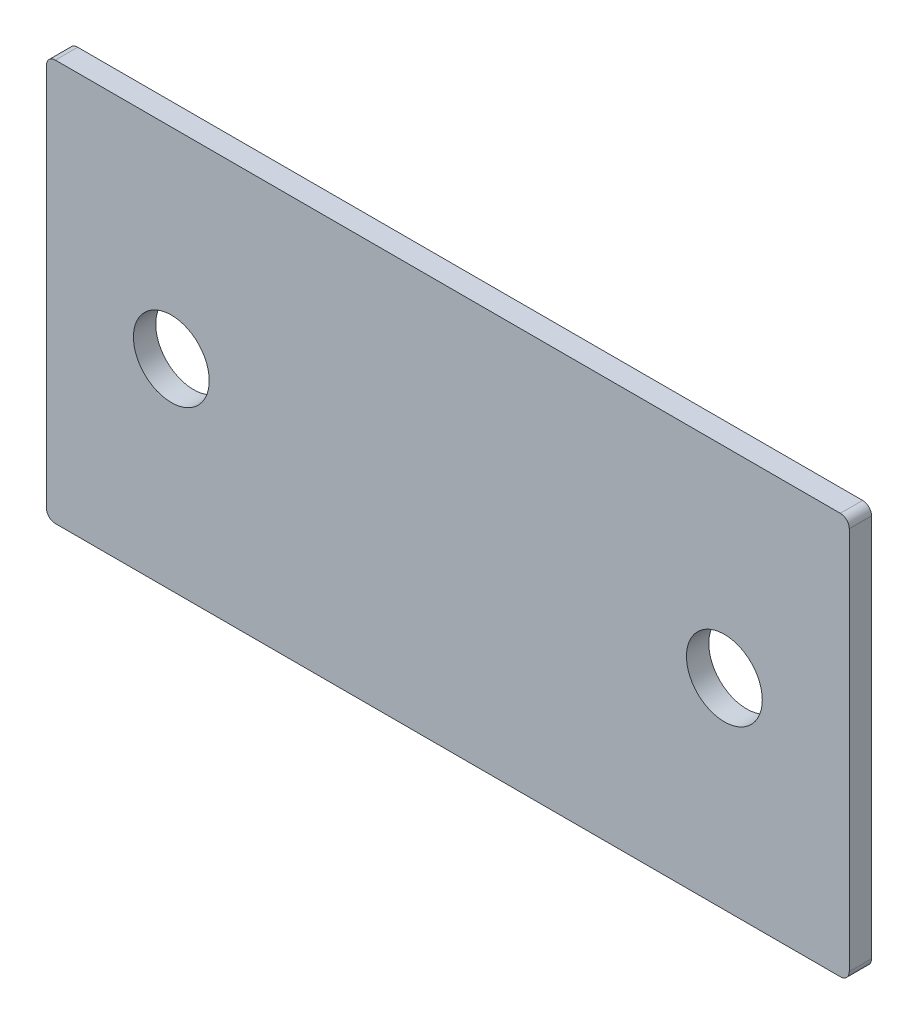
from build123d import *

# Parameters (mm, degrees)
SKETCH_1_W      = 90
SKETCH_1_H      = 45
SKETCH_1_R      = 4.25
EXTRUDE_1_DEPTH = 2.5
FILLET_1_R      = 1


with BuildPart() as part:
    # Эскиз1 → Бобышка-Вытянуть1 (new body)
    with BuildSketch(Plane.XY):
        Rectangle(SKETCH_1_W, SKETCH_1_H)
        with Locations((-31, 0)):
            Circle(SKETCH_1_R, mode=Mode.SUBTRACT)
        with Locations((31, 0)):
            Circle(SKETCH_1_R, mode=Mode.SUBTRACT)
    extrude(amount=EXTRUDE_1_DEPTH)

    # Скругление1
    fillet_1_edges = [part.edges().sort_by_distance(p)[0] for p in [
        (45, -22.5, 1.25),
        (-45, -22.5, 1.25),
        (-45, 22.5, 1.25),
        (45, 22.5, 1.25),
    ]]
    fillet(fillet_1_edges, radius=FILLET_1_R)


solid = part.part
